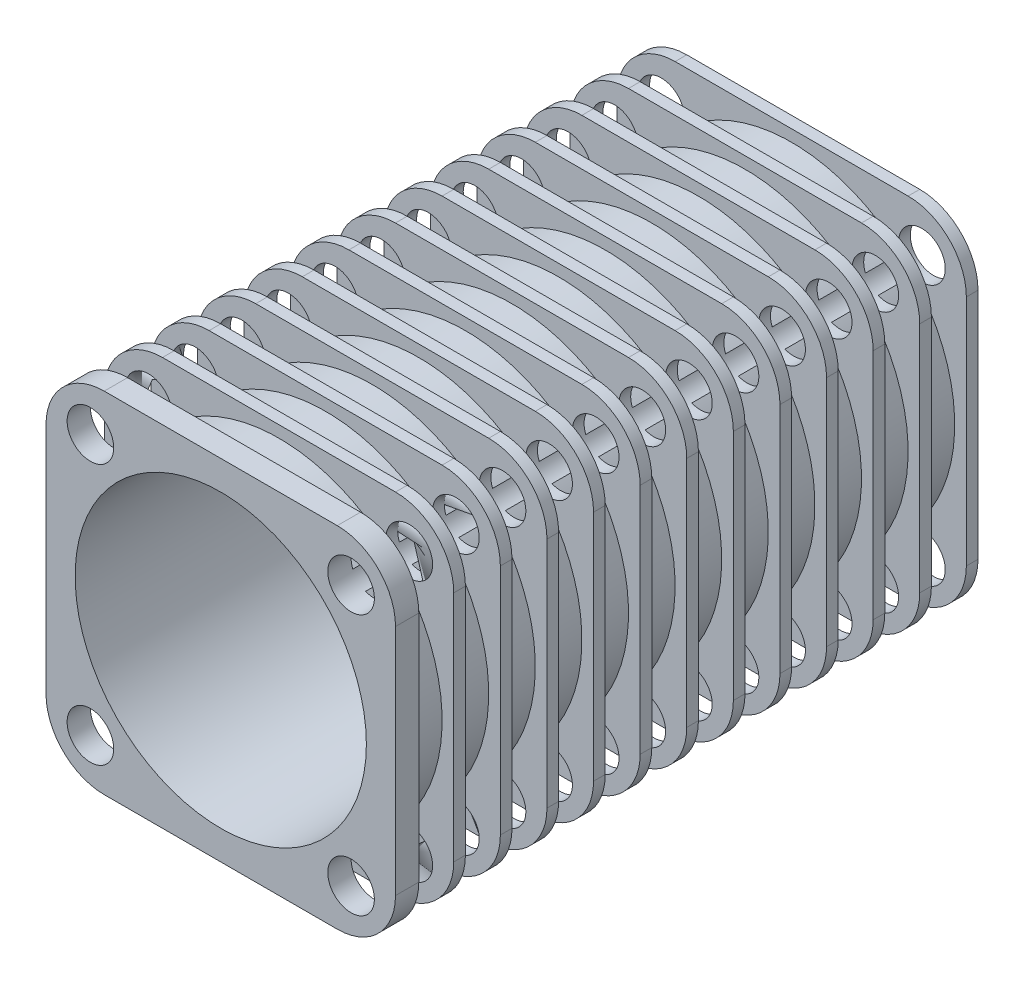
from build123d import *

# Parameters (mm, degrees)
SKETCH1_W           = 30
SKETCH1_H           = 30
SKETCH1_R           = 12.5
BOSS_EXTRUDE1_DEPTH = 50
FILLET1_R           = 5
SKETCH4_W           = 15
SKETCH4_H           = 3
LPATTERN4_COUNT     = 12
LPATTERN4_PITCH     = 4
SKETCH9_R           = 2
CUT_EXTRUDE1_DEPTH  = 51
CIRPATTERN1_COUNT   = 4


with BuildPart() as part:
    # Sketch1 → Boss-Extrude1 (new body)
    with BuildSketch(Plane.XY):
        Rectangle(SKETCH1_W, SKETCH1_H)
        Circle(SKETCH1_R, mode=Mode.SUBTRACT)
    extrude(amount=BOSS_EXTRUDE1_DEPTH)

    # Fillet1
    fillet1_edges = [part.edges().sort_by_distance(p)[0] for p in [
        (-15, 15, 25),
        (15, 15, 25),
        (15, -15, 25),
        (-15, -15, 25),
    ]]
    fillet(fillet1_edges, radius=FILLET1_R)

    # Sketch4 → Cut-Revolve1 (revolve, cut)
    with BuildSketch(Plane(origin=(0, 0, 0), x_dir=(1, 0, 0), z_dir=(0, 1, 0))):
        with Locations((-21.5, -2.5)):
            Rectangle(SKETCH4_W, SKETCH4_H)
    cut_revolve1 = revolve(axis=Axis((0, 0, 0), (0, 0, 1)), mode=Mode.SUBTRACT)

    # LPattern4: Cut-Revolve1 ×12
    with Locations(*[(0, 0, i * LPATTERN4_PITCH) for i in range(1, LPATTERN4_COUNT)]):
        add(cut_revolve1, mode=Mode.SUBTRACT)

    # Sketch9 → Cut-Extrude1 (cut, through all)
    with BuildSketch(Plane.XY.offset(50)):
        with Locations((-11.187184335, 11.187184335)):
            Circle(SKETCH9_R)
    cut_extrude1 = extrude(amount=-CUT_EXTRUDE1_DEPTH, mode=Mode.SUBTRACT)

    # CirPattern1: Cut-Extrude1 ×4 about axis
    cirpattern1_axis = Axis((0, 0, 0), (0, 0, 1))
    for i in range(1, CIRPATTERN1_COUNT):
        add(cut_extrude1.rotate(cirpattern1_axis, i * 360 / CIRPATTERN1_COUNT), mode=Mode.SUBTRACT)


solid = part.part
